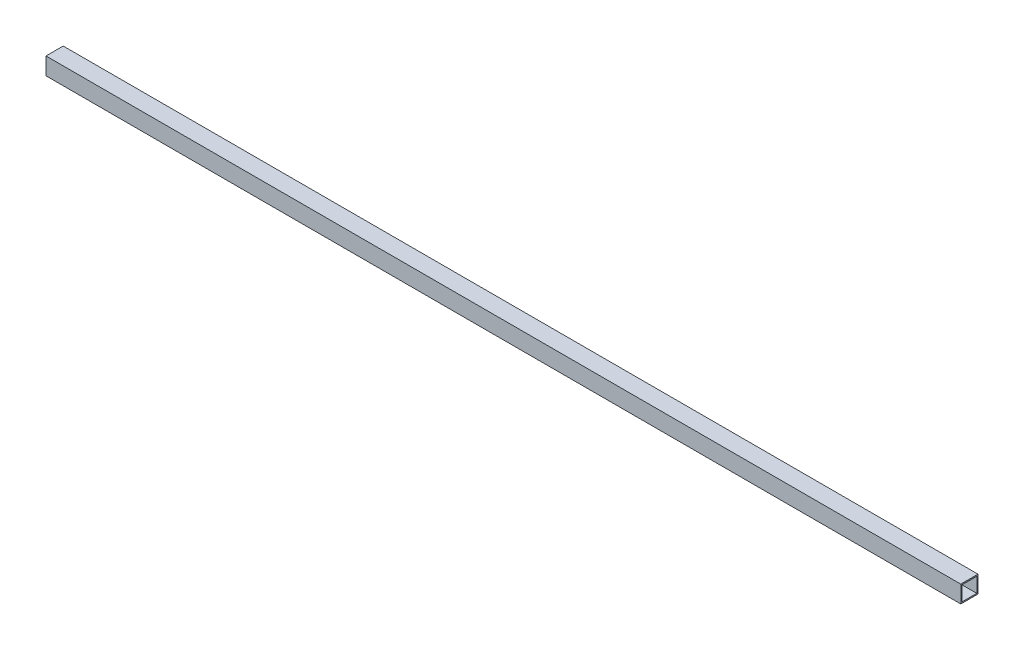
from build123d import *

# Parameters (mm, degrees)
SKETCH1_W           = 2360.422
SKETCH1_H           = 44.45
BOSS_EXTRUDE1_DEPTH = 44.45
SHELL1_T            = -3.175


with BuildPart() as part:
    # Sketch1 → Boss-Extrude1 (new body)
    with BuildSketch(Plane.XY):
        with Locations((1180.211, 22.225)):
            Rectangle(SKETCH1_W, SKETCH1_H)
    extrude(amount=BOSS_EXTRUDE1_DEPTH)

    # Shell1
    shell1_openings = [part.faces().sort_by_distance(p)[0] for p in [
        (2360.422, 22.225, 22.225),
        (0, 22.225, 22.225),
    ]]
    offset(amount=SHELL1_T, openings=shell1_openings, kind=Kind.INTERSECTION)


solid = part.part
